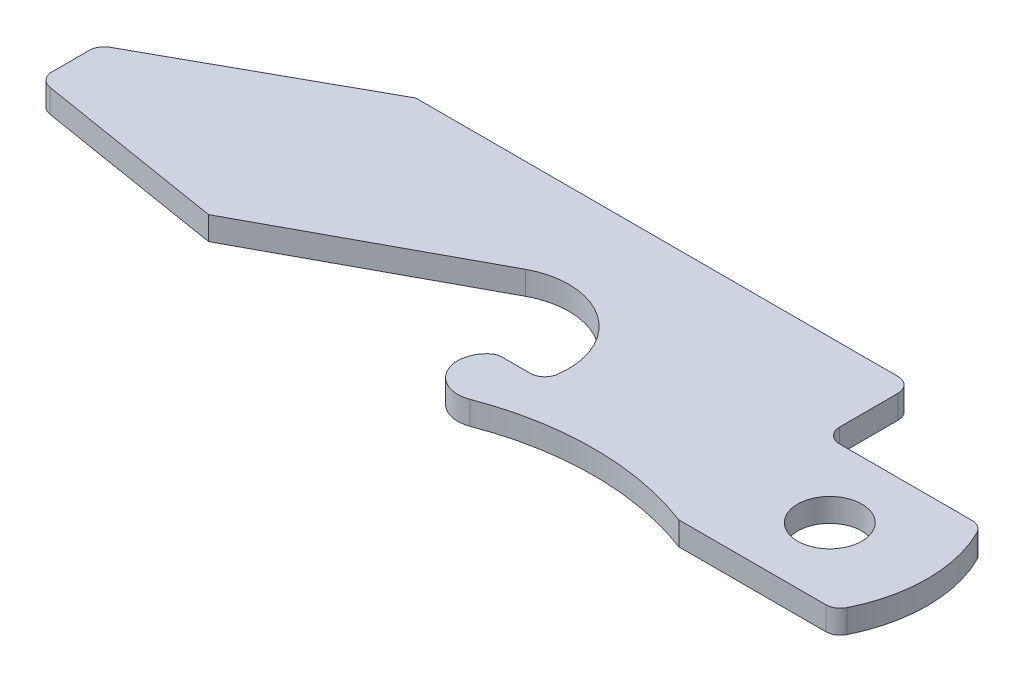
from build123d import *

# Parameters (mm, degrees)
SKETCH1_R           = 1.397
BOSS_EXTRUDE1_DEPTH = 1.016
FILLET1_R           = 0.635
CUT_EXTRUDE1_DEPTH  = 0.381
CUT_EXTRUDE1_TAPER  = 5


with BuildPart() as part:
    # Sketch1 → Boss-Extrude1 (new body)
    with BuildSketch(Plane(origin=(0, 0, 0), x_dir=(1, 0, 0), z_dir=(0, 1, 0))):
        with BuildLine():
            Line((0, 0), (0, -2.54))
            Line((0, -2.54), (8.774021221, -3.97131115))
            Line((8.774021221, -3.97131115), (17.714676902, 0.85468885))
            ThreePointArc((17.714676902, 0.85468885), (21.270106923, 0.487494578), (22.230837366, -2.95531115))
            Line((22.230837366, -2.95531115), (20.32, -2.95531115))
            ThreePointArc((20.32, -2.95531115), (19.80856952, -4.601146953), (21.40873402, -5.24131115))
            ThreePointArc((21.40873402, -5.24131115), (25.94436701, -4.403774359), (30.48, -5.24131115))
            Line((30.48, -5.24131115), (37.249261314, -5.24131115))
            ThreePointArc((37.249261314, -5.24131115), (38.1, -2.06631115), (37.249261314, 1.10868885))
            Line((37.249261314, 1.10868885), (30.48, 1.10868885))
            Line((30.48, 1.10868885), (30.48, 4.91868885))
            Line((30.48, 4.91868885), (8.89, 4.91868885))
            Line((8.89, 4.91868885), (0, 0))
        make_face()
        with Locations((33.864630657, -2.06631115)):
            Circle(SKETCH1_R, mode=Mode.SUBTRACT)
    extrude(amount=BOSS_EXTRUDE1_DEPTH)

    # Fillet1
    fillet1_edges = [part.edges().sort_by_distance(p)[0] for p in [
        (30.48, 0.508, -4.91868885),
        (30.48, 0.508, -1.10868885),
        (37.249261314, 0.508, -1.10868885),
        (37.249261314, 0.508, 5.24131115),
        (20.32, 0.508, 2.95531115),
        (22.230837366, 0.508, 2.95531115),
        (0, 0.508, 2.54),
        (0, 0.508, 0),
    ]]
    fillet(fillet1_edges, radius=FILLET1_R)

    # Sketch3 → Cut-Extrude1 (cut)
    with BuildSketch(Plane(origin=(0, -0.841145333, -0.148316617), x_dir=(-1, 0, 0), z_dir=(0, -0.984807753, -0.173648178))):
        with BuildLine():
            ThreePointArc((-17.78, 3.750389462), (-13.335, 2.559355302), (-8.89, 3.750389462))
            Line((-8.89, 3.750389462), (-17.78, 3.750389462))
        make_face()
    extrude(amount=-CUT_EXTRUDE1_DEPTH, taper=CUT_EXTRUDE1_TAPER, mode=Mode.SUBTRACT)


solid = part.part
